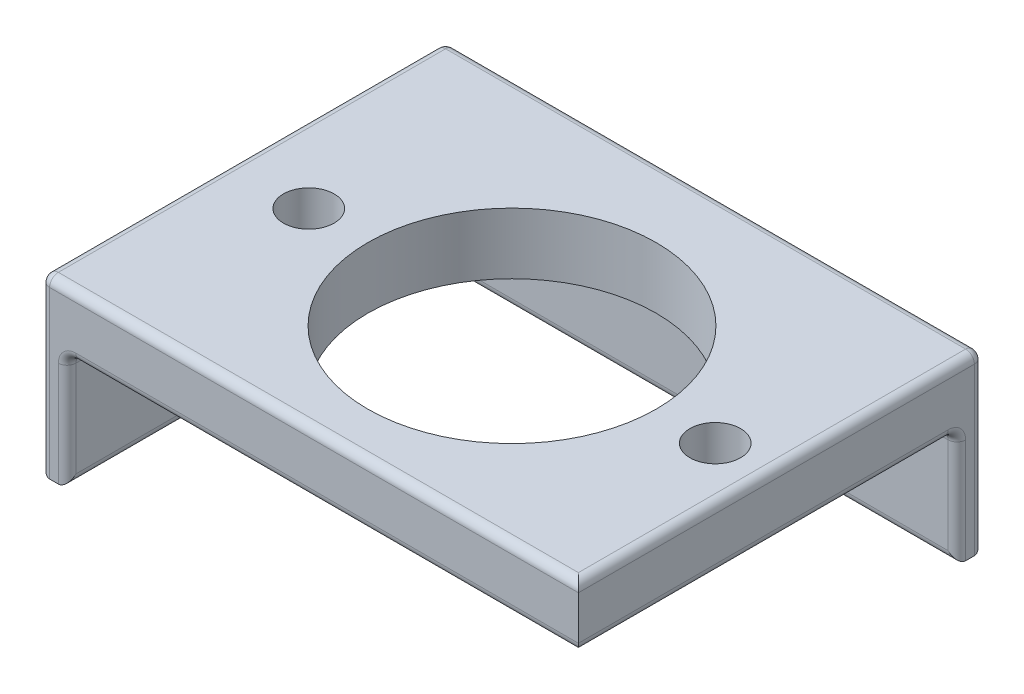
from build123d import *

# Parameters (mm, degrees)
SKETCH1_W                = 58.5
SKETCH1_H                = 43.3
SKETCH1_R                = 16.5
BOSS_EXTRUDE1_DEPTH      = 7
M5_CLEARANCE_HOLE1_D     = 5.8
M5_CLEARANCE_HOLE1_DEPTH = 7
SKETCH5_W                = 58.5
SKETCH5_H                = 19.98
BOSS_EXTRUDE2_DEPTH      = 3
SKETCH6_W                = 46.3
SKETCH6_H                = 19.98
BOSS_EXTRUDE3_DEPTH      = 3
M5_CLEARANCE_HOLE2_D     = 5.5
M5_CLEARANCE_HOLE2_DEPTH = 3
M5_CLEARANCE_HOLE3_D     = 5.5
M5_CLEARANCE_HOLE3_DEPTH = 3
FILLET1_R                = 1
FILLET2_R                = 1


with BuildPart() as part:
    # Sketch1 → Boss-Extrude1 (new body)
    with BuildSketch(Plane(origin=(0, 0, 0), x_dir=(1, 0, 0), z_dir=(0, 1, 0))):
        Rectangle(SKETCH1_W, SKETCH1_H)
        Circle(SKETCH1_R, mode=Mode.SUBTRACT)
    extrude(amount=BOSS_EXTRUDE1_DEPTH)

    # M5 Clearance Hole1
    with Locations(Plane(origin=(0, 7, 0), x_dir=(1, 0, 0), z_dir=(0, 1, 0))):
        with Locations((-23.25, 0), (23.25, 0)):
            Hole(M5_CLEARANCE_HOLE1_D / 2, depth=M5_CLEARANCE_HOLE1_DEPTH)

    # Sketch5 → Boss-Extrude2 (add)
    with BuildSketch(Plane(origin=(0, 0, -21.65), x_dir=(-1, 0, 0), z_dir=(0, 0, -1))):
        with Locations((0, -2.99)):
            Rectangle(SKETCH5_W, SKETCH5_H)
    extrude(amount=BOSS_EXTRUDE2_DEPTH)

    # Sketch6 → Boss-Extrude3 (add)
    with BuildSketch(Plane.ZY.offset(29.25)):
        with Locations((-1.5, -2.99)):
            Rectangle(SKETCH6_W, SKETCH6_H)
    extrude(amount=BOSS_EXTRUDE3_DEPTH)

    # M5 Clearance Hole2
    with Locations(Plane.XY.offset(-21.65)):
        with Locations((-17, -4.79), (17, -4.79)):
            Hole(M5_CLEARANCE_HOLE2_D / 2, depth=M5_CLEARANCE_HOLE2_DEPTH)

    # M5 Clearance Hole3
    with Locations(Plane(origin=(-29.25, 0, 0), x_dir=(0, 0, -1), z_dir=(1, 0, 0))):
        with Locations((-11.65, -4.79), (11.65, -4.79)):
            Hole(M5_CLEARANCE_HOLE3_D / 2, depth=M5_CLEARANCE_HOLE3_DEPTH)

    # Fillet1
    fillet1_edges = [part.edges().sort_by_distance(p)[0] for p in [
        (-29.25, -6.49, -21.65),
        (29.25, -6.49, -21.65),
        (0, -12.98, -21.65),
        (-29.25, -12.98, 0),
        (-29.25, -6.49, 21.65),
        (0, 0, -21.65),
        (29.25, 0, 0),
        (0, 0, 21.65),
        (-29.25, 0, 0),
    ]]
    fillet(fillet1_edges, radius=FILLET1_R)

    # Fillet2
    fillet2_edges = [part.edges().sort_by_distance(p)[0] for p in [
        (29.25, 7, -1.5),
        (-1.5, 7, -24.65),
        (29.25, -2.99, -24.65),
        (-1.5, -12.98, -24.65),
        (-32.25, -2.99, -24.65),
        (-32.25, -12.98, -1.5),
        (-32.25, -2.99, 21.65),
        (-32.25, 7, -1.5),
        (-1.5, 7, 21.65),
    ]]
    fillet(fillet2_edges, radius=FILLET2_R)


solid = part.part
